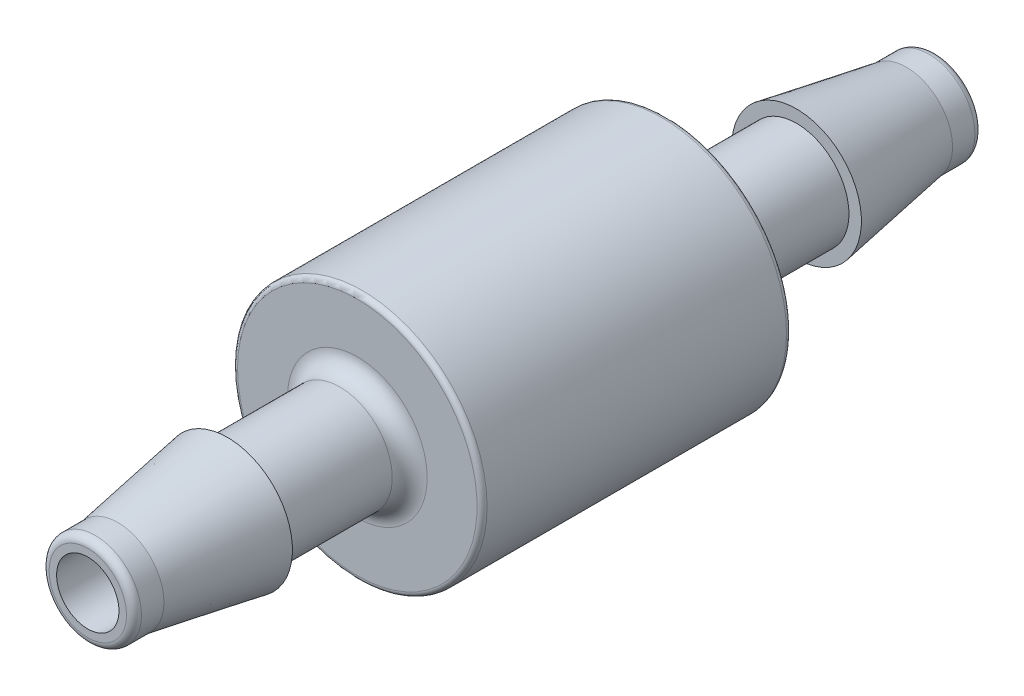
from build123d import *


with BuildPart() as part:
    # Sketch2 → Revolve1 (revolve)
    with BuildSketch(Plane(origin=(0, 0, 0), x_dir=(0, 0, -1), z_dir=(1, 0, 0))):
        with BuildLine():
            Line((-21.59, 1.5875), (-21.59, 1.9685))
            ThreePointArc((-21.59, 1.9685), (-21.478407684, 2.237907684), (-21.209, 2.3495))
            Line((-21.209, 2.3495), (-20.066, 2.3495))
            Line((-20.066, 2.3495), (-14.478, 3.302))
            Line((-14.478, 3.302), (-14.478, 2.667))
            Line((-14.478, 2.667), (-8.763, 2.667))
            ThreePointArc((-8.763, 2.667), (-8.134382072, 2.927382072), (-7.874, 3.556))
            Line((-7.874, 3.556), (-7.874, 6.096))
            ThreePointArc((-7.874, 6.096), (-7.799605122, 6.275605122), (-7.62, 6.35))
            Line((-7.62, 6.35), (7.62, 6.35))
            ThreePointArc((7.62, 6.35), (7.799605122, 6.275605122), (7.874, 6.096))
            Line((7.874, 6.096), (7.874, 3.556))
            ThreePointArc((7.874, 3.556), (8.134382072, 2.927382072), (8.763, 2.667))
            Line((8.763, 2.667), (14.478, 2.667))
            Line((14.478, 2.667), (14.478, 3.302))
            Line((14.478, 3.302), (20.066, 2.3495))
            Line((20.066, 2.3495), (21.209, 2.3495))
            ThreePointArc((21.209, 2.3495), (21.478407684, 2.237907684), (21.59, 1.9685))
            Line((21.59, 1.9685), (21.59, 1.5875))
            Line((21.59, 1.5875), (-21.59, 1.5875))
        make_face()
    revolve(axis=Axis((0, 0, -21.59), (0, 0, 1)))


solid = part.part
